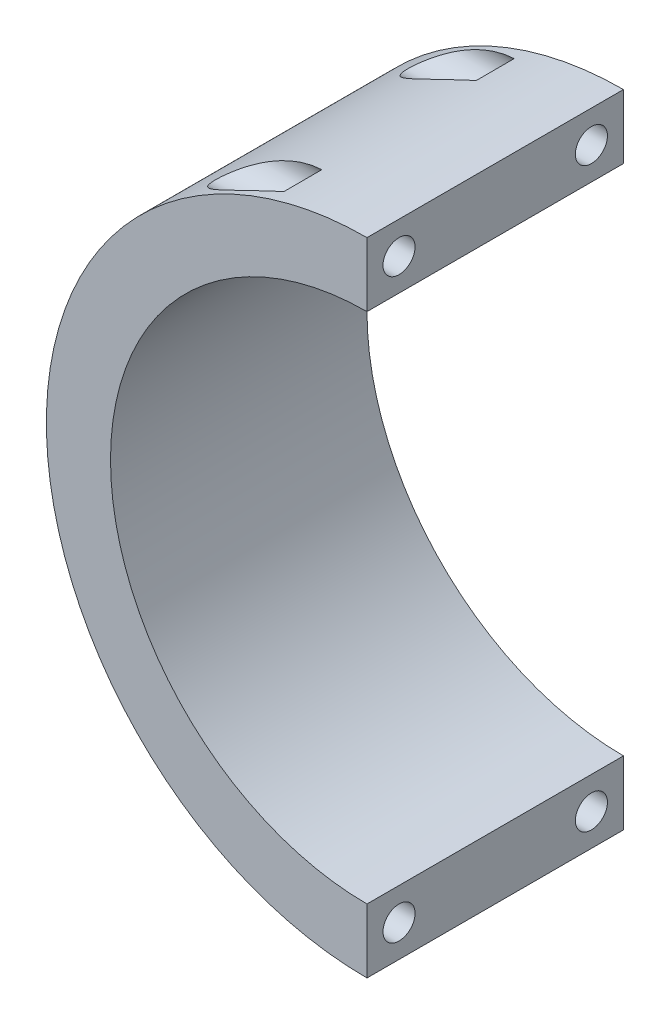
from build123d import *

# Parameters (mm, degrees)
BOSS_EXTRUDE1_DEPTH = 50.8
SKETCH2_R           = 3.175
CUT_EXTRUDE1_DEPTH  = 64.5
SKETCH3_R           = 5.08
CUT_EXTRUDE2_DEPTH  = 19.05


with BuildPart() as part:
    # Sketch1 → Boss-Extrude1 (new body)
    with BuildSketch(Plane.XY):
        with BuildLine():
            Line((0, 101.6), (0, 114.3))
            ThreePointArc((0, 114.3), (-63.5, 50.8), (0, -12.7))
            Line((0, -12.7), (0, 0))
            ThreePointArc((0, 0), (-50.8, 50.8), (0, 101.6))
        make_face()
    extrude(amount=BOSS_EXTRUDE1_DEPTH)

    # Sketch2 → Cut-Extrude1 (cut, through all)
    with BuildSketch(Plane(origin=(0, 0, 0), x_dir=(0, 0, -1), z_dir=(1, 0, 0))):
        with Locations((-44.45, 107.95)):
            Circle(SKETCH2_R)
        with Locations((-6.35, 107.95)):
            Circle(SKETCH2_R)
        with Locations((-6.35, -6.35)):
            Circle(SKETCH2_R)
        with Locations((-44.45, -6.35)):
            Circle(SKETCH2_R)
    extrude(amount=-CUT_EXTRUDE1_DEPTH, mode=Mode.SUBTRACT)

    # Sketch3 → Cut-Extrude2 (cut)
    with BuildSketch(Plane(origin=(-38.1, 0, 0), x_dir=(0, 0, -1), z_dir=(1, 0, 0))):
        with Locations((-44.45, 107.95)):
            Circle(SKETCH3_R)
        with Locations((-6.35, 107.95)):
            Circle(SKETCH3_R)
        with Locations((-6.35, -6.35)):
            Circle(SKETCH3_R)
        with Locations((-44.45, -6.35)):
            Circle(SKETCH3_R)
    extrude(amount=CUT_EXTRUDE2_DEPTH, mode=Mode.SUBTRACT)


solid = part.part
